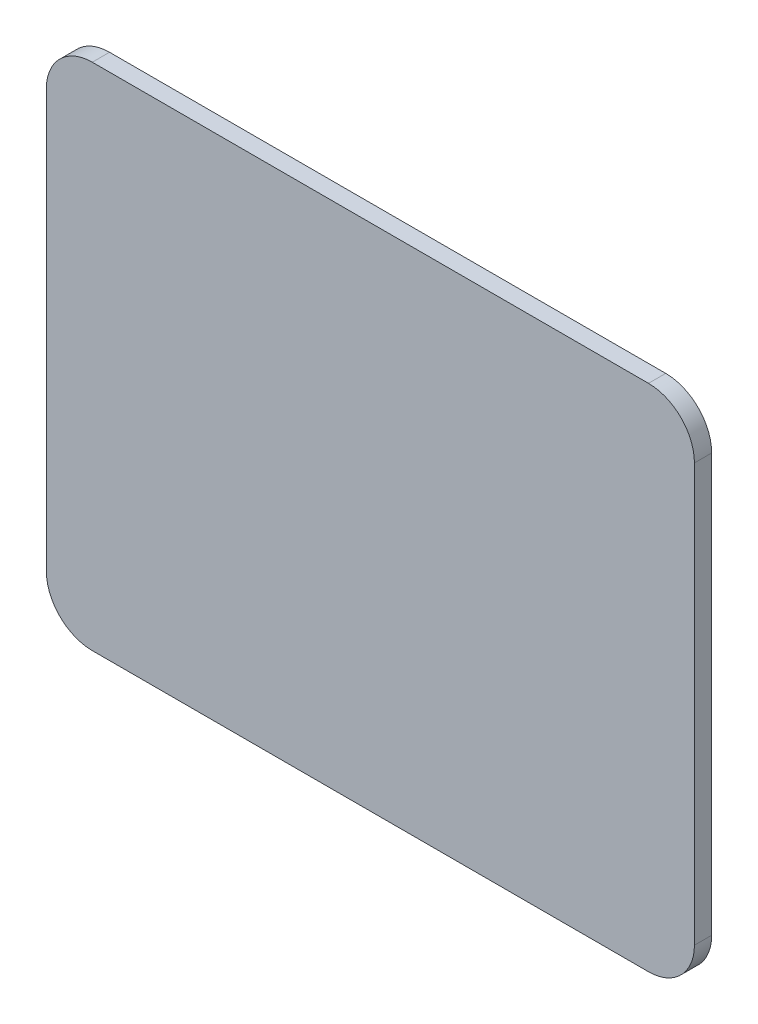
from build123d import *

# Parameters (mm, degrees)
BOSS_EXTRUDE1_DEPTH = 6


with BuildPart() as part:
    # Sketch1 → Boss-Extrude1 (new body)
    with BuildSketch(Plane.XY):
        with BuildLine():
            Line((250.35, 26), (250.35, 171.4))
            ThreePointArc((250.35, 171.4), (245.663708499, 182.713708499), (234.35, 187.4))
            Line((234.35, 187.4), (40.731266216, 187.4))
            ThreePointArc((40.731266216, 187.4), (29.417557717, 182.713708499), (24.731266216, 171.4))
            Line((24.731266216, 171.4), (24.731266216, 26))
            ThreePointArc((24.731266216, 26), (29.417557717, 14.686291501), (40.731266216, 10))
            Line((40.731266216, 10), (234.35, 10))
            ThreePointArc((234.35, 10), (245.663708499, 14.686291501), (250.35, 26))
        make_face()
    extrude(amount=BOSS_EXTRUDE1_DEPTH)


solid = part.part
